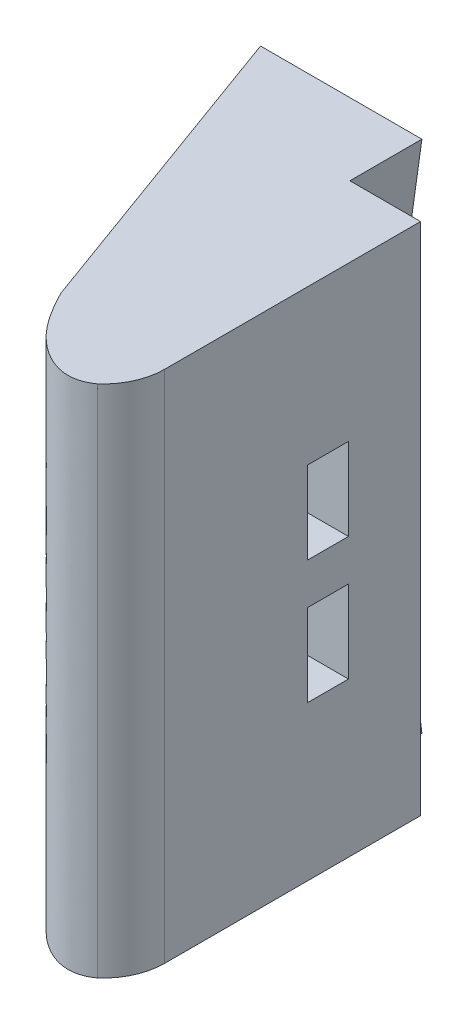
from build123d import *

# Parameters (mm, degrees)
BOSS_EXTRUDE1_DEPTH  = 50
SKETCH2_R            = 1.6
CUT_EXTRUDE1_DEPTH   = 20
SKETCH4_W            = 4
SKETCH4_H            = 8
CUT_EXTRUDE2_DEPTH   = 12
BOSS_EXTRUDE4_DEPTH  = 7
BOSS_EXTRUDE12_DEPTH = 12.57
BOSS_EXTRUDE13_DEPTH = 12.57


with BuildPart() as part:
    # Sketch1 → Boss-Extrude1 (new body)
    with BuildSketch(Plane(origin=(0, 0, 0), x_dir=(1, 0, 0), z_dir=(0, 1, 0))):
        with BuildLine():
            Line((0, 0), (20, 0))
            Line((20, 0), (20, -24.855700299))
            ThreePointArc((20, -24.855700299), (19.469946725, -27.31925094), (17.973595405, -29.34680389))
            add(Edge.make_bspline(
                [(17.973595405, -29.34680389), (16.281120611, -30.60167495), (11.87635292, -29.319904822), (9.598231396, -25.56159513), (8.550503583, -23.49231552)],
                knots=[0, 0, 0, 0, 0.430742711, 1, 1, 1, 1], degree=3))
            Line((8.550503583, -23.49231552), (0, 0))
        make_face()
    extrude(amount=BOSS_EXTRUDE1_DEPTH)

    # Sketch2 → Cut-Extrude1 (cut)
    with BuildSketch(Plane(origin=(0, 0, 0), x_dir=(-1, 0, 0), z_dir=(0, 0, -1))):
        with Locations((-14, 31)):
            Circle(SKETCH2_R)
        with Locations((-14, 19)):
            Circle(SKETCH2_R)
    extrude(amount=-CUT_EXTRUDE1_DEPTH, mode=Mode.SUBTRACT)

    # Sketch4 → Cut-Extrude2 (cut)
    with BuildSketch(Plane(origin=(20, 0, 0), x_dir=(0, 0, -1), z_dir=(1, 0, 0))):
        with Locations((-9, 19)):
            Rectangle(SKETCH4_W, SKETCH4_H)
        with Locations((-9, 31)):
            Rectangle(SKETCH4_W, SKETCH4_H)
    extrude(amount=-CUT_EXTRUDE2_DEPTH, mode=Mode.SUBTRACT)

    # Sketch5 → Boss-Extrude4 (add)
    with BuildSketch(Plane(origin=(0, 0, 0), x_dir=(-1, 0, 0), z_dir=(0, 0, -1))):
        Polygon((-11.369100365, 37.428714266), (-12.760831375, 47.331394953), (-13.135879356, 50), (0, 50), (0, 37.428714266), align=None)
        Polygon((0, 12.571285734), (-11.369100365, 12.571285734), (-12.760831375, 2.668605047), (-13.135879356, 0), (0, 0), align=None)
    extrude(amount=BOSS_EXTRUDE4_DEPTH)

    # Sketch7 → Boss-Extrude12 (add)
    with BuildSketch(Plane(origin=(0, 50, 0), x_dir=(1, 0, 0), z_dir=(0, 1, 0))):
        Polygon((0, 0), (0, 7), (-2.54779164, 7), align=None)
    extrude(amount=-BOSS_EXTRUDE12_DEPTH)

    # Sketch8 → Boss-Extrude13 (add)
    with BuildSketch(Plane(origin=(0, 0, 0), x_dir=(-1, 0, 0), z_dir=(0, -1, 0))):
        Polygon((0, 0), (2.54779164, 7), (0, 7), align=None)
    extrude(amount=-BOSS_EXTRUDE13_DEPTH)


solid = part.part
